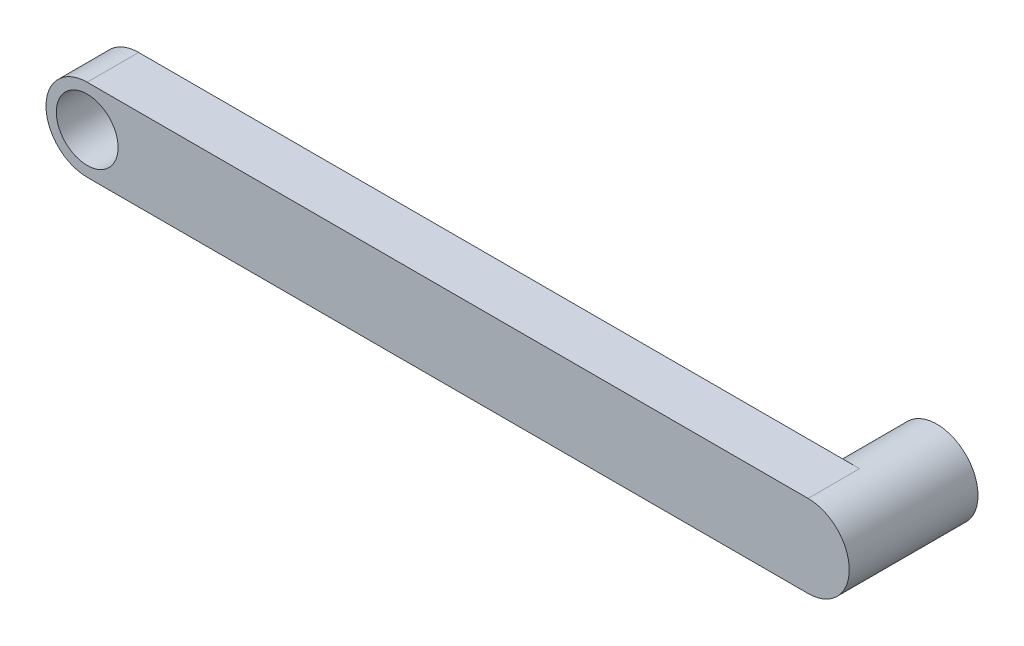
from build123d import *

# Parameters (mm, degrees)
SKETCH1_R           = 6
BOSS_EXTRUDE1_DEPTH = 10
BOSS_EXTRUDE2_START = -15
BOSS_EXTRUDE2_DEPTH = 15


with BuildPart() as part:
    # Sketch1 → Boss-Extrude1 (new body)
    with BuildSketch(Plane.XY):
        with BuildLine():
            Line((190, 8), (50, 8))
            ThreePointArc((50, 8), (42, 0), (50, -8))
            Line((50, -8), (190, -8))
            ThreePointArc((190, -8), (198, 0), (190, 8))
        make_face()
        with Locations((50, 0)):
            Circle(SKETCH1_R, mode=Mode.SUBTRACT)
    extrude(amount=BOSS_EXTRUDE1_DEPTH)

    # Sketch1_6 → Boss-Extrude2 (add)
    with BuildSketch(Plane.XY.offset(BOSS_EXTRUDE2_START)):
        with BuildLine():
            ThreePointArc((198, 0), (195.656854249, 5.656854249), (190, 8))
            ThreePointArc((190, 8), (182, 0), (190, -8))
            ThreePointArc((190, -8), (195.656854249, -5.656854249), (198, 0))
        make_face()
    extrude(amount=BOSS_EXTRUDE2_DEPTH)


solid = part.part
